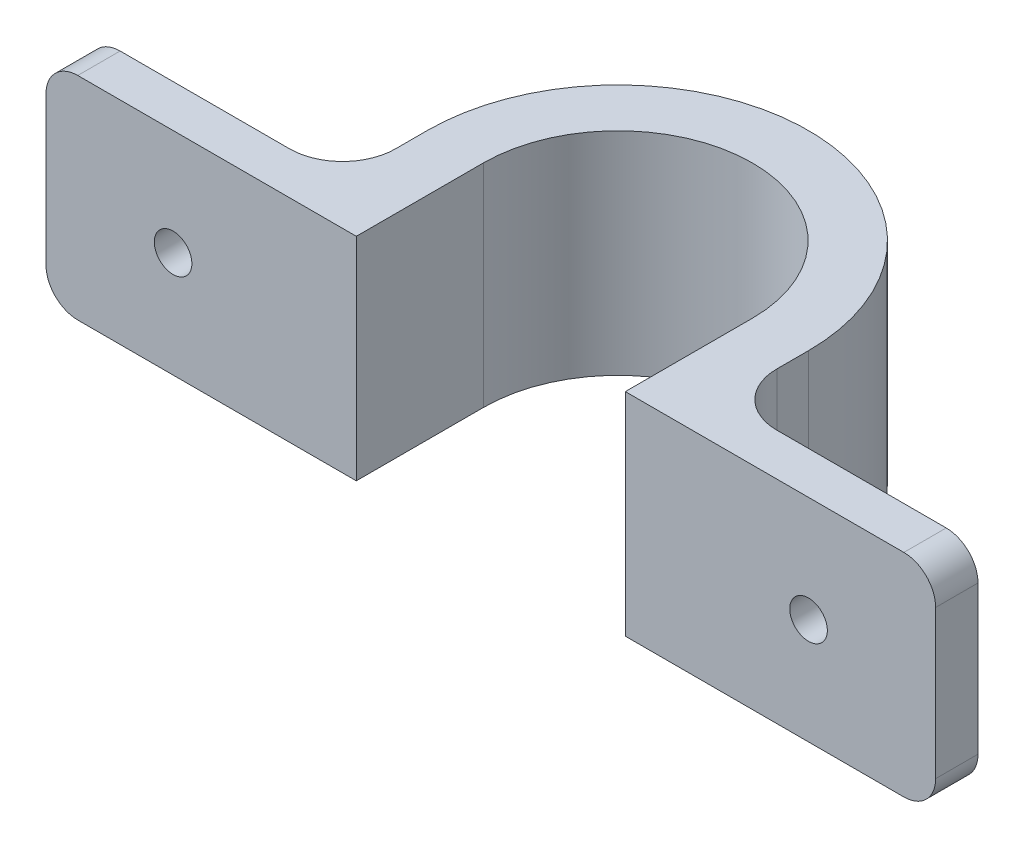
from build123d import *

# Parameters (mm, degrees)
BOSS_EXTRUDE1_DEPTH = 20
SKETCH2_R           = 1.775
CUT_EXTRUDE1_DEPTH  = 5
FILLET1_R           = 3
FILLET2_R           = 5


with BuildPart() as part:
    # Sketch1 → Boss-Extrude1 (new body)
    with BuildSketch(Plane(origin=(0, 0, 0), x_dir=(1, 0, 0), z_dir=(0, 1, 0))):
        with BuildLine():
            Line((0, 0), (0, 4))
            Line((0, 4), (24, 4))
            Line((24, 4), (24, 12))
            ThreePointArc((24, 12), (42, 30), (60, 12))
            Line((60, 12), (60, 4))
            Line((60, 4), (84, 4))
            Line((84, 4), (84, 0))
            Line((84, 0), (54.7, 0))
            Line((54.7, 0), (54.7, 12))
            ThreePointArc((54.7, 12), (42, 24.7), (29.3, 12))
            Line((29.3, 12), (29.3, 0))
            Line((29.3, 0), (0, 0))
        make_face()
    extrude(amount=BOSS_EXTRUDE1_DEPTH)

    # Sketch2 → Cut-Extrude1 (cut, through all)
    with BuildSketch(Plane(origin=(0, 0, -4), x_dir=(-1, 0, 0), z_dir=(0, 0, -1))):
        with Locations((-72, 10)):
            Circle(SKETCH2_R)
        with Locations((-12, 10)):
            Circle(SKETCH2_R)
    extrude(amount=-CUT_EXTRUDE1_DEPTH, mode=Mode.SUBTRACT)

    # Fillet1
    fillet1_edges = [part.edges().sort_by_distance(p)[0] for p in [
        (0, 0, -2),
        (84, 0, -2),
        (84, 20, -2),
        (0, 20, -2),
    ]]
    fillet(fillet1_edges, radius=FILLET1_R)

    # Fillet2
    fillet2_edges = [part.edges().sort_by_distance(p)[0] for p in [
        (24, 10, -4),
        (60, 10, -4),
    ]]
    fillet(fillet2_edges, radius=FILLET2_R)


solid = part.part
